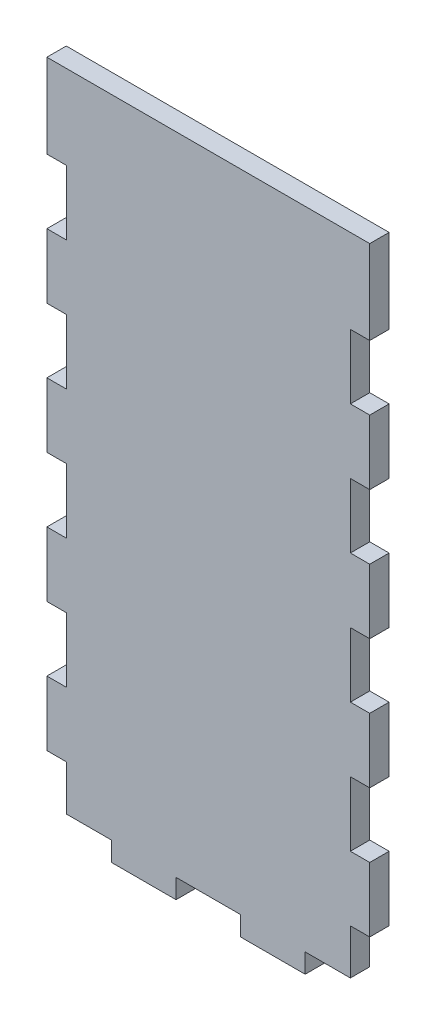
from build123d import *

# Parameters (mm, degrees)
SKETCH1_W               = 100
SKETCH1_H               = 206
BOSS_EXTRUDE1_DEPTH     = 6
SKETCH2_W               = 6
SKETCH2_H               = 20
CUT_EXTRUDE1_DEPTH      = 10
LPATTERN1_COUNT         = 5
LPATTERN1_PITCH         = 40
MIRROR2_COPY_1_SKETCH_W = 6
MIRROR2_COPY_1_SKETCH_H = 20
MIRROR2_COPY_1_DEPTH    = 10
MIRROR2_COPY_2_SKETCH_W = 6
MIRROR2_COPY_2_SKETCH_H = 20
MIRROR2_COPY_2_DEPTH    = 10
MIRROR2_COPY_3_SKETCH_W = 6
MIRROR2_COPY_3_SKETCH_H = 20
MIRROR2_COPY_3_DEPTH    = 10
MIRROR2_COPY_4_SKETCH_W = 6
MIRROR2_COPY_4_SKETCH_H = 20
MIRROR2_COPY_4_DEPTH    = 10
SKETCH4_W               = 20
SKETCH4_H               = 6
CUT_EXTRUDE2_DEPTH      = 10
LPATTERN2_COUNT         = 3
LPATTERN2_PITCH         = 40


with BuildPart() as part:
    # Sketch1 → Boss-Extrude1 (new body)
    with BuildSketch(Plane.XY):
        with Locations((40, 96.427419355)):
            Rectangle(SKETCH1_W, SKETCH1_H)
    extrude(amount=BOSS_EXTRUDE1_DEPTH)

    # Sketch2 → Cut-Extrude1 (cut)
    with BuildSketch(Plane.XY):
        with Locations((-7, 3.427419355)):
            Rectangle(SKETCH2_W, SKETCH2_H)
    cut_extrude1 = extrude(amount=CUT_EXTRUDE1_DEPTH, mode=Mode.SUBTRACT)

    # LPattern1: Cut-Extrude1 ×5
    with Locations(*[(0, i * LPATTERN1_PITCH, 0) for i in range(1, LPATTERN1_COUNT)]):
        add(cut_extrude1, mode=Mode.SUBTRACT)

    # Mirror2: Cut-Extrude1 across plane
    add(cut_extrude1.mirror(Plane(origin=(40, 0, 0), x_dir=(0, 0, 1), z_dir=(1, 0, 0))), mode=Mode.SUBTRACT)

    # Mirror2 copy 1 sketch → Mirror2 copy 1 (cut)
    with BuildSketch(Plane(origin=(80, 40, 0), x_dir=(-1, 0, 0), z_dir=(0, 0, 1))):
        with Locations((-7, -3.427419355)):
            Rectangle(MIRROR2_COPY_1_SKETCH_W, MIRROR2_COPY_1_SKETCH_H)
    extrude(amount=MIRROR2_COPY_1_DEPTH, mode=Mode.SUBTRACT)

    # Mirror2 copy 2 sketch → Mirror2 copy 2 (cut)
    with BuildSketch(Plane(origin=(80, 80, 0), x_dir=(-1, 0, 0), z_dir=(0, 0, 1))):
        with Locations((-7, -3.427419355)):
            Rectangle(MIRROR2_COPY_2_SKETCH_W, MIRROR2_COPY_2_SKETCH_H)
    extrude(amount=MIRROR2_COPY_2_DEPTH, mode=Mode.SUBTRACT)

    # Mirror2 copy 3 sketch → Mirror2 copy 3 (cut)
    with BuildSketch(Plane(origin=(80, 120, 0), x_dir=(-1, 0, 0), z_dir=(0, 0, 1))):
        with Locations((-7, -3.427419355)):
            Rectangle(MIRROR2_COPY_3_SKETCH_W, MIRROR2_COPY_3_SKETCH_H)
    extrude(amount=MIRROR2_COPY_3_DEPTH, mode=Mode.SUBTRACT)

    # Mirror2 copy 4 sketch → Mirror2 copy 4 (cut)
    with BuildSketch(Plane(origin=(80, 160, 0), x_dir=(-1, 0, 0), z_dir=(0, 0, 1))):
        with Locations((-7, -3.427419355)):
            Rectangle(MIRROR2_COPY_4_SKETCH_W, MIRROR2_COPY_4_SKETCH_H)
    extrude(amount=MIRROR2_COPY_4_DEPTH, mode=Mode.SUBTRACT)

    # Sketch4 → Cut-Extrude2 (cut)
    with BuildSketch(Plane.XY.offset(6)):
        with Locations((0, -3.572580645)):
            Rectangle(SKETCH4_W, SKETCH4_H)
    cut_extrude2 = extrude(amount=-CUT_EXTRUDE2_DEPTH, mode=Mode.SUBTRACT)

    # LPattern2: Cut-Extrude2 ×3
    with Locations(*[(i * LPATTERN2_PITCH, 0, 0) for i in range(1, LPATTERN2_COUNT)]):
        add(cut_extrude2, mode=Mode.SUBTRACT)


solid = part.part
